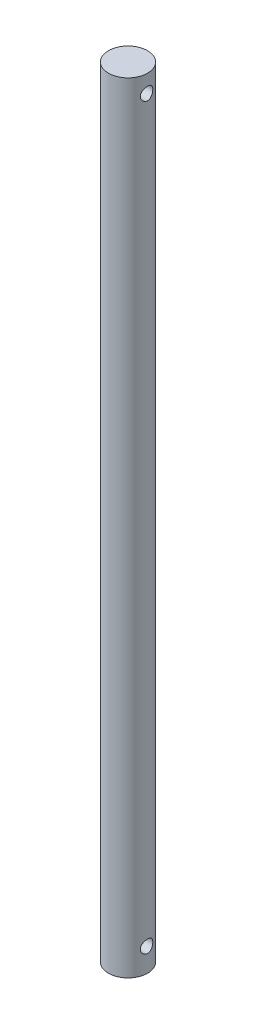
from build123d import *

# Parameters (mm, degrees)
SKETCH1_W               = 10
SKETCH1_H               = 399.034
SKETCH2_R               = 3.2
CUT_EXTRUDE1_DEPTH      = 11
CUT_EXTRUDE1_DEPTH_BACK = 11


with BuildPart() as part:
    # Sketch1 → Revolve2 (revolve)
    with BuildSketch(Plane(origin=(0, 0, 0), x_dir=(0, 0, -1), z_dir=(1, 0, 0))):
        with Locations((-5, 199.517)):
            Rectangle(SKETCH1_W, SKETCH1_H)
    revolve(axis=Axis((0, 0, 0), (0, 1, 0)))

    # Sketch2 → Cut-Extrude1 (cut, two sides)
    with BuildSketch(Plane(origin=(0, 0, 0), x_dir=(0, 0, -1), z_dir=(1, 0, 0))) as cut_extrude1_sk:
        with Locations((0, 390.034)):
            Circle(SKETCH2_R)
        with Locations((0, 12)):
            Circle(SKETCH2_R)
    extrude(amount=CUT_EXTRUDE1_DEPTH, mode=Mode.SUBTRACT)
    extrude(cut_extrude1_sk.sketch, amount=-CUT_EXTRUDE1_DEPTH_BACK, mode=Mode.SUBTRACT)


solid = part.part
